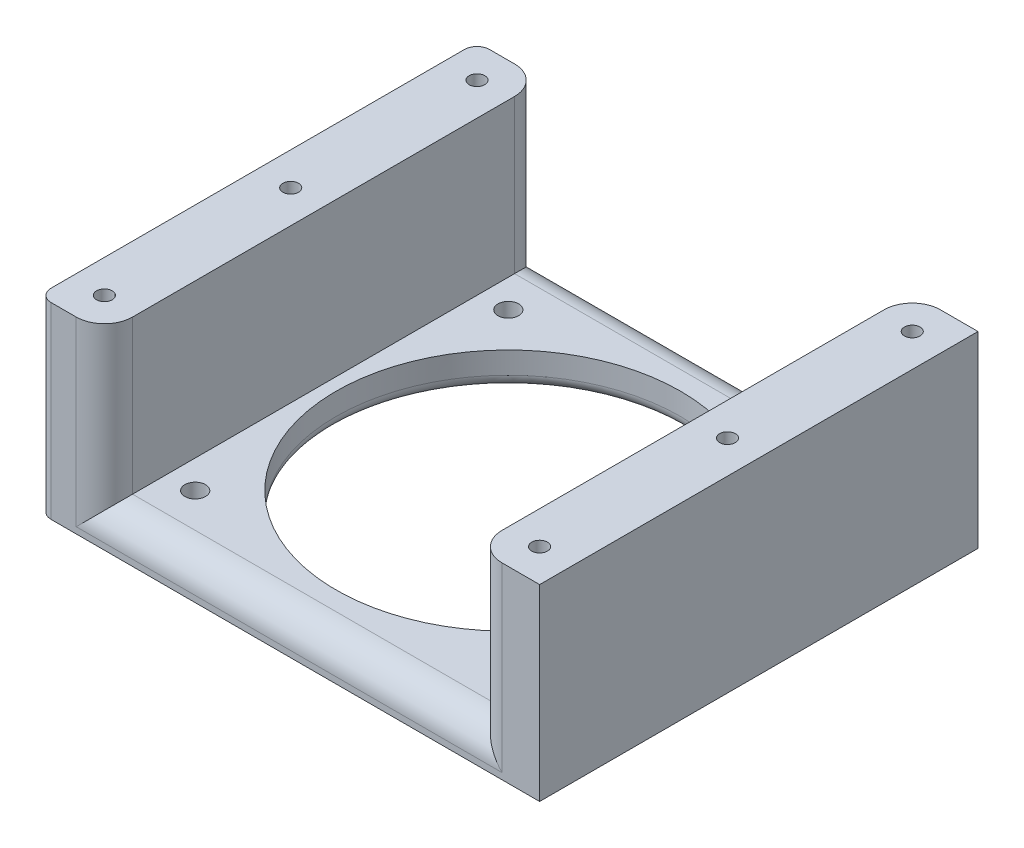
from build123d import *

# Parameters (mm, degrees)
SKETCH1_W                       = 80
SKETCH1_H                       = 70
BOSS_EXTRUDE1_DEPTH             = 35.5
CUT_EXTRUDE1_REACH              = 72
SKETCH2_W                       = 59
SKETCH2_H                       = 24.5
SKETCH6_R                       = 27.5
CUT_EXTRUDE3_DEPTH              = 5.5
M4X0_7_TAPPED_HOLE1_D           = 3.3
M4X0_7_TAPPED_HOLE1_DEPTH       = 5.5
FILLET2_R                       = 2
SKETCH9_W                       = 80
SKETCH9_H                       = 70
CUT_EXTRUDE5_DEPTH              = 5.5
TAP_DRILL_FOR_M3X0_5_TAP1_D     = 2.5
TAP_DRILL_FOR_M3X0_5_TAP1_DEPTH = 15
TAP_DRILL_FOR_M3X0_5_TAP1_TIP   = 0.751075774
FILLET5_R                       = 2
FILLET6_R                       = 2
FILLET7_R                       = 4.5
FILLET8_R                       = 4.5
TAP_DRILL_FOR_M3X0_5_TAP2_D     = 2.5
TAP_DRILL_FOR_M3X0_5_TAP2_DEPTH = 15
TAP_DRILL_FOR_M3X0_5_TAP2_TIP   = 0.751075774


with BuildPart() as part:
    # Sketch1 → Boss-Extrude1 (new body)
    with BuildSketch(Plane(origin=(0, 0, 0), x_dir=(1, 0, 0), z_dir=(0, 1, 0))):
        with Locations((-2.631253278, 2.602774632)):
            Rectangle(SKETCH1_W, SKETCH1_H)
    extrude(amount=BOSS_EXTRUDE1_DEPTH)

    # Sketch2 → Cut-Extrude1 (cut, up to next)
    with BuildSketch(Plane.XY.offset(32.397225368), mode=Mode.PRIVATE) as cut_extrude1_sk1:
        with Locations((-2.631253278, 17.75)):
            Rectangle(SKETCH2_W, SKETCH2_H)
    cut_extrude1_tool1 = extrude(cut_extrude1_sk1.sketch, amount=-CUT_EXTRUDE1_REACH, mode=Mode.PRIVATE) & part.part
    add(cut_extrude1_tool1.solids().sort_by_distance((-2.631253, 17.75, 32.397225))[0], mode=Mode.SUBTRACT)

    # Sketch6 → Cut-Extrude3 (cut)
    with BuildSketch(Plane.XZ):
        with Locations(Location((-2.631253278, -2.602774632, 0), (0, 0, 270))):  # turned: the seam where the file's is
            Circle(SKETCH6_R)
    extrude(amount=-CUT_EXTRUDE3_DEPTH, mode=Mode.SUBTRACT)

    # M4x0.7 Tapped Hole1
    with Locations(Plane(origin=(22.368746722, 0, 22.397225368), x_dir=(0, 0, -1), z_dir=(0, -1, 0))):
        with Locations((0, 0), (50, 0), (50, -50), (0, -50)):
            Hole(M4X0_7_TAPPED_HOLE1_D / 2, depth=M4X0_7_TAPPED_HOLE1_DEPTH)

    # Fillet2
    fillet2_edges = [part.edges().sort_by_distance(p)[0] for p in [
        (-2.631253278, 0, 24.897225368),
    ]]
    fillet(fillet2_edges, radius=FILLET2_R)

    # Sketch9 → Cut-Extrude5 (cut)
    with BuildSketch(Plane(origin=(0, 35.5, 0), x_dir=(-1, 0, 0), z_dir=(0, 1, 0))):
        with Locations((2.631253278, -2.602774632)):
            Rectangle(SKETCH9_W, SKETCH9_H)
    extrude(amount=-CUT_EXTRUDE5_DEPTH, mode=Mode.SUBTRACT)

    # Tap Drill for M3x0.5 Tap1
    with Locations(Plane(origin=(-37.381253278, 30, -32.352774632), x_dir=(0, 0, 1), z_dir=(0, 1, 0))):
        with Locations((0, 0), (29.75, 0), (59.5, 0), (0, 69.5), (29.5, 69.5), (59.5, 69.5)):
            Hole(TAP_DRILL_FOR_M3X0_5_TAP1_D / 2, depth=TAP_DRILL_FOR_M3X0_5_TAP1_DEPTH)
            with Locations((0, 0, -(TAP_DRILL_FOR_M3X0_5_TAP1_DEPTH + TAP_DRILL_FOR_M3X0_5_TAP1_TIP / 2))):  # 118° drill point
                Cone(0, TAP_DRILL_FOR_M3X0_5_TAP1_D / 2, TAP_DRILL_FOR_M3X0_5_TAP1_TIP, mode=Mode.SUBTRACT)

    # Fillet5
    fillet5_edges = [part.edges().sort_by_distance(p)[0] for p in [
        (-42.631253278, 15, 32.397225368),
    ]]
    fillet(fillet5_edges, radius=FILLET5_R)

    # Fillet6
    fillet6_edges = [part.edges().sort_by_distance(p)[0] for p in [
        (-42.631253278, 15, -37.602774632),
    ]]
    fillet(fillet6_edges, radius=FILLET6_R)

    # Fillet7
    fillet7_edges = [part.edges().sort_by_distance(p)[0] for p in [
        (-32.131253278, 17.75, 32.397225368),
        (-2.631253278, 5.5, 32.397225368),
        (26.868746722, 17.75, 32.397225368),
    ]]
    fillet(fillet7_edges, radius=FILLET7_R)

    # Fillet8
    fillet8_edges = [part.edges().sort_by_distance(p)[0] for p in [
        (-2.631253278, 5.5, -37.602774632),
        (-32.131253278, 17.75, -37.602774632),
        (26.868746722, 17.75, -37.602774632),
    ]]
    fillet(fillet8_edges, radius=FILLET8_R)

    # Tap Drill for M3x0.5 Tap2
    with Locations(Plane(origin=(32.618746722, 0, 12.397225368), x_dir=(0, 0, -1), z_dir=(0, -1, 0))):
        with Locations((0, 0), (30, 0), (0, -70.5), (30, -70.5)):
            Hole(TAP_DRILL_FOR_M3X0_5_TAP2_D / 2, depth=TAP_DRILL_FOR_M3X0_5_TAP2_DEPTH)
            with Locations((0, 0, -(TAP_DRILL_FOR_M3X0_5_TAP2_DEPTH + TAP_DRILL_FOR_M3X0_5_TAP2_TIP / 2))):  # 118° drill point
                Cone(0, TAP_DRILL_FOR_M3X0_5_TAP2_D / 2, TAP_DRILL_FOR_M3X0_5_TAP2_TIP, mode=Mode.SUBTRACT)


solid = part.part
